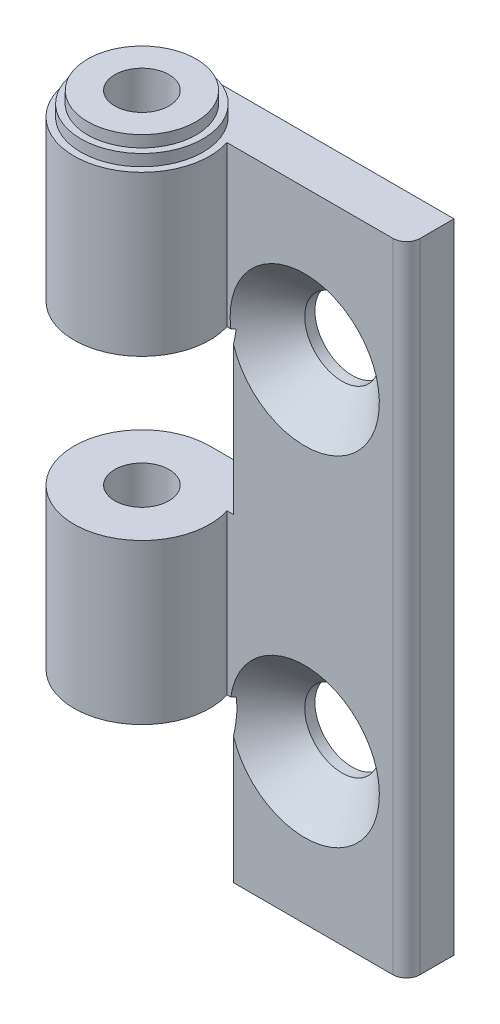
from build123d import *

# Parameters (mm, degrees)
SKETCH1_W               = 5
SKETCH1_H               = 47
SKETCH2_W               = 18
SKETCH2_H               = 47
BOSS_EXTRUDE1_DEPTH     = 3.5
CUT_EXTRUDE1_DEPTH      = 47
CUT_EXTRUDE1_DEPTH_BACK = 47
SKETCH3_W               = 94
SKETCH3_H               = 94
SKETCH5_W               = 2
SKETCH5_H               = 53.4
CUT_EXTRUDE2_DEPTH      = 23.5
CUT_EXTRUDE2_DEPTH_BACK = 23.5


with BuildPart() as part:
    # Sketch1 → Revolve1 (revolve)
    with BuildSketch(Plane.XY):
        with Locations((2.5, 0)):
            Rectangle(SKETCH1_W, SKETCH1_H)
    revolve(axis=Axis((0, -23.5, 0), (0, 1, 0)))

    # Sketch2 → Boss-Extrude1 (add)
    with BuildSketch(Plane.XY.offset(-5)):
        with Locations((9, 0)):
            Rectangle(SKETCH2_W, SKETCH2_H)
    extrude(amount=BOSS_EXTRUDE1_DEPTH)

    # Sketch3 → Cut-Extrude1 (cut, two sides: drawn at the far end of the back side and taken through both)
    with BuildSketch(Plane.XY.offset(-CUT_EXTRUDE1_DEPTH_BACK)):
        Rectangle(SKETCH3_W, SKETCH3_H)
        Polygon((-5, 23.5), (-5, 11.75), (5.25, 11.75), (5.25, 0), (-5, 0), (-5, -11.75), (5.25, -11.75), (5.25, -23.5), (18, -23.5), (18, 23.5), align=None, mode=Mode.SUBTRACT)
    extrude(amount=CUT_EXTRUDE1_DEPTH + CUT_EXTRUDE1_DEPTH_BACK, mode=Mode.SUBTRACT)

    # Sketch4 → Revolve2 (revolve)
    with BuildSketch(Plane.XY):
        Polygon((0, 25.2), (4, 25.2), (4, 24.35), (4.5, 24.35), (4.5, 23.5), (0, 23.5), align=None)
    revolve(axis=Axis((0, 23.5, 0), (0, 1, 0)))

    # Sketch5 → Cut-Revolve1 (revolve, cut)
    with BuildSketch(Plane.XY):
        with Locations((1, 0)):
            Rectangle(SKETCH5_W, SKETCH5_H)
    revolve(axis=Axis((0, -26.7, 0), (0, 1, 0)), mode=Mode.SUBTRACT)

    # Sketch6 → Cut-Revolve2 (revolve, cut)
    with BuildSketch(Plane(origin=(10.5, 0, 0), x_dir=(0, 0, -1), z_dir=(1, 0, 0))):
        Polygon((5, -12.5), (5, -15.25), (4.25, -15.25), (1.5, -18), (1.5, -12.5), align=None)
    revolve(axis=Axis((10.5, -12.5, -1.5), (0, 0, -1)), mode=Mode.SUBTRACT)

    # Sketch7 → Cut-Revolve3 (revolve, cut)
    with BuildSketch(Plane(origin=(10.5, 0, 0), x_dir=(0, 0, -1), z_dir=(1, 0, 0))):
        Polygon((5, 12.5), (5, 9.75), (4.25, 9.75), (1.5, 7), (1.5, 12.5), align=None)
    revolve(axis=Axis((10.5, 12.5, -1.5), (0, 0, -1)), mode=Mode.SUBTRACT)

    # Sketch8 → Cut-Extrude2 (cut, two sides: drawn at the far end of the back side and taken through both)
    with BuildSketch(Plane(origin=(0, 0, 0), x_dir=(1, 0, 0), z_dir=(0, 1, 0)).offset(-CUT_EXTRUDE2_DEPTH_BACK)):
        with BuildLine():
            Line((17, 1.5), (18, 1.5))
            Line((18, 1.5), (18, 2.5))
            ThreePointArc((18, 2.5), (17.707106781, 1.792893219), (17, 1.5))
        make_face()
    extrude(amount=CUT_EXTRUDE2_DEPTH + CUT_EXTRUDE2_DEPTH_BACK, mode=Mode.SUBTRACT)


solid = part.part
